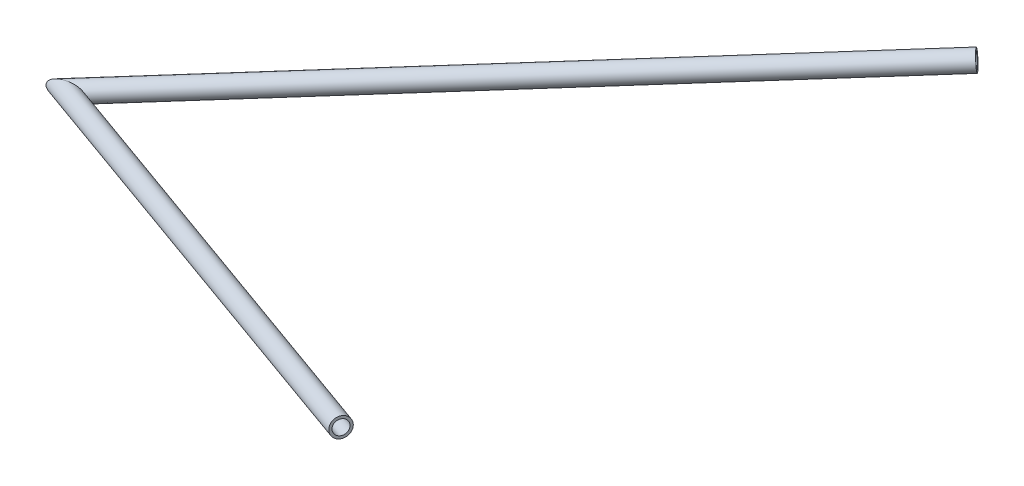
from build123d import *

# Parameters (mm, degrees)
SKETCH1_ON_SEGMENT_1_R                         = 9.525
SKETCH1_ON_SEGMENT_1_R_2                       = 6.985
PIPE_STANDARD_S40_PIPE_1_SCH_40_1_DEPTH        = 553.706791842
SKETCH1_R                                      = 9.525
SKETCH1_R_2                                    = 6.985
PIPE_STANDARD_S40_PIPE_1_SCH_40_1_2_DEPTH      = 658.924913325
PIPE_STANDARD_S40_PIPE_1_SCH_40_1_2_DEPTH_BACK = 22.184562768


with BuildPart() as part:
    # Sketch1 on segment 1 (carried to segment 1) → Pipe standard s40 PIPE 1 SCH 40_1 (new body)
    with BuildSketch(Plane(origin=(435, -124.6, 206.8), x_dir=(-0.374119399, -0.143337301, 0.916236374), z_dir=(-0.916236374, -0.095574554, -0.389071216))):
        Circle(SKETCH1_ON_SEGMENT_1_R)
        Circle(SKETCH1_ON_SEGMENT_1_R_2, mode=Mode.SUBTRACT)
    extrude(amount=PIPE_STANDARD_S40_PIPE_1_SCH_40_1_DEPTH)

    # Pipe standard s40 PIPE 1 SCH 40_1 mitre
    split(bisect_by=Plane(origin=(-52, -175.4, 0), x_dir=(0, -0.999847575, 0.017459287), z_dir=(0.165079115, 0.017219752, 0.986129994)), keep=Keep.TOP)


with BuildPart() as body_2:
    # Sketch1 → Pipe standard s40 PIPE 1 SCH 40_1 2 (new, two sides)
    with BuildSketch(Plane(origin=(-52, -175.4, 0), x_dir=(-0.651221412426134, -0.17224239784648918, -0.7390826938724806), z_dir=(0.7390826938724807, 0.0770952789501411, -0.6691883812364028))) as pipe_standard_s40_pipe_1_sch_40_1_2_sk:
        Circle(SKETCH1_R)
        Circle(SKETCH1_R_2, mode=Mode.SUBTRACT)
    extrude(amount=PIPE_STANDARD_S40_PIPE_1_SCH_40_1_2_DEPTH)
    extrude(pipe_standard_s40_pipe_1_sch_40_1_2_sk.sketch, amount=-PIPE_STANDARD_S40_PIPE_1_SCH_40_1_2_DEPTH_BACK)

    # Pipe standard s40 PIPE 1 SCH 40_1 2 mitr
    split(bisect_by=Plane(origin=(-52, -175.4, 0), x_dir=(0, 0.999847575, -0.017459287), z_dir=(-0.165079115, -0.017219752, -0.986129994)), keep=Keep.TOP)


solid = Compound([part.part, body_2.part])
